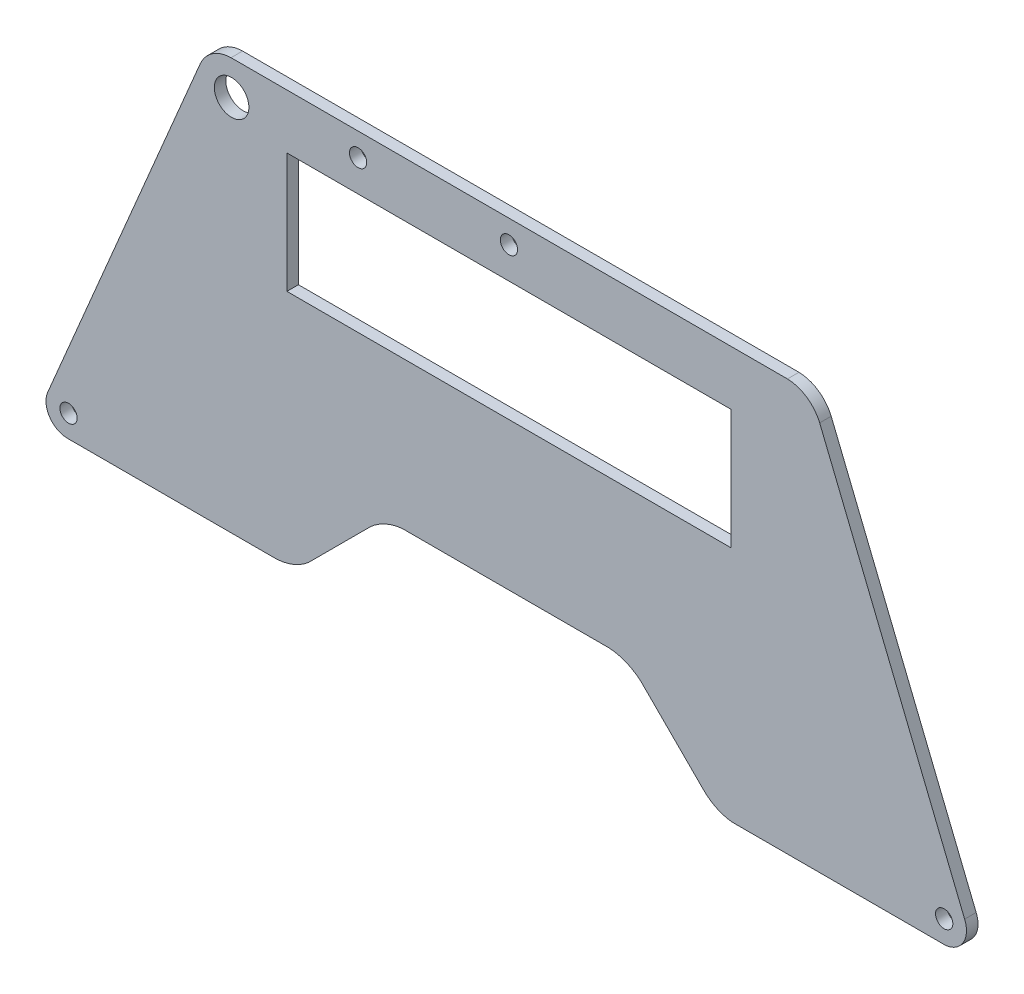
from build123d import *

# Parameters (mm, degrees)
ESBO_O1_R                = 2.998945894
ESBO_O1_R_2              = 1.5
RESSALTO_EXTRUS_O1_DEPTH = 2
ESBO_O3_W                = 77.000000909
ESBO_O3_H                = 20.799996635
CORTE_EXTRUS_O2_DEPTH    = 3


with BuildPart() as part:
    # Esboço1 → Ressalto-extrusão1 (new body)
    with BuildSketch(Plane.XY):
        with BuildLine():
            Line((-0.452, 5.715), (-25.598, 67.691))
            ThreePointArc((-25.598, 67.691), (-27.830124117, 70.420084628), (-31.186, 71.501))
            Line((-31.186, 71.501), (-127.706, 71.501))
            ThreePointArc((-127.706, 71.501), (-130.895769937, 70.507154905), (-133.04, 67.945))
            Line((-133.04, 67.945), (-159.456, 5.461))
            ThreePointArc((-159.456, 5.461), (-159.249042624, 1.900068852), (-156.154, 0.127))
            Line((-156.154, 0.127), (-119.832, 0.127))
            ThreePointArc((-119.832, 0.127), (-116.845272565, 0.798888491), (-114.244, 2.413))
            Line((-114.244, 2.413), (-103.576, 13.081))
            ThreePointArc((-103.576, 13.081), (-100.992547951, 14.814205491), (-97.988, 15.621))
            Line((-97.988, 15.621), (-62.174, 15.621))
            ThreePointArc((-62.174, 15.621), (-59.187272565, 14.949111509), (-56.586, 13.335))
            Line((-56.586, 13.335), (-45.918, 2.667))
            ThreePointArc((-45.918, 2.667), (-43.605600005, 0.941799989), (-40.838, 0.127))
            Line((-40.838, 0.127), (-3.754, 0.127))
            ThreePointArc((-3.754, 0.127), (-0.686880545, 2.08420214), (-0.452, 5.715))
        make_face()
        with Locations((-127.610794879, 65.579692319)):
            Circle(ESBO_O1_R, mode=Mode.SUBTRACT)
        with Locations((-105.664, 67.501)):
            Circle(ESBO_O1_R_2, mode=Mode.SUBTRACT)
        with Locations((-79.5, 67.501)):
            Circle(ESBO_O1_R_2, mode=Mode.SUBTRACT)
        with Locations((-4, 4)):
            Circle(ESBO_O1_R_2, mode=Mode.SUBTRACT)
        with Locations((-155.893, 4)):
            Circle(ESBO_O1_R_2, mode=Mode.SUBTRACT)
    extrude(amount=RESSALTO_EXTRUS_O1_DEPTH)

    # Esboço3 → Corte-extrusão2 (cut, through all)
    with BuildSketch(Plane(origin=(0, 0, 0), x_dir=(-1, 0, 0), z_dir=(0, 0, -1))):
        with Locations((79.512001037, 51.64081955)):
            Rectangle(ESBO_O3_W, ESBO_O3_H)
    extrude(amount=-CORTE_EXTRUS_O2_DEPTH, mode=Mode.SUBTRACT)


solid = part.part
